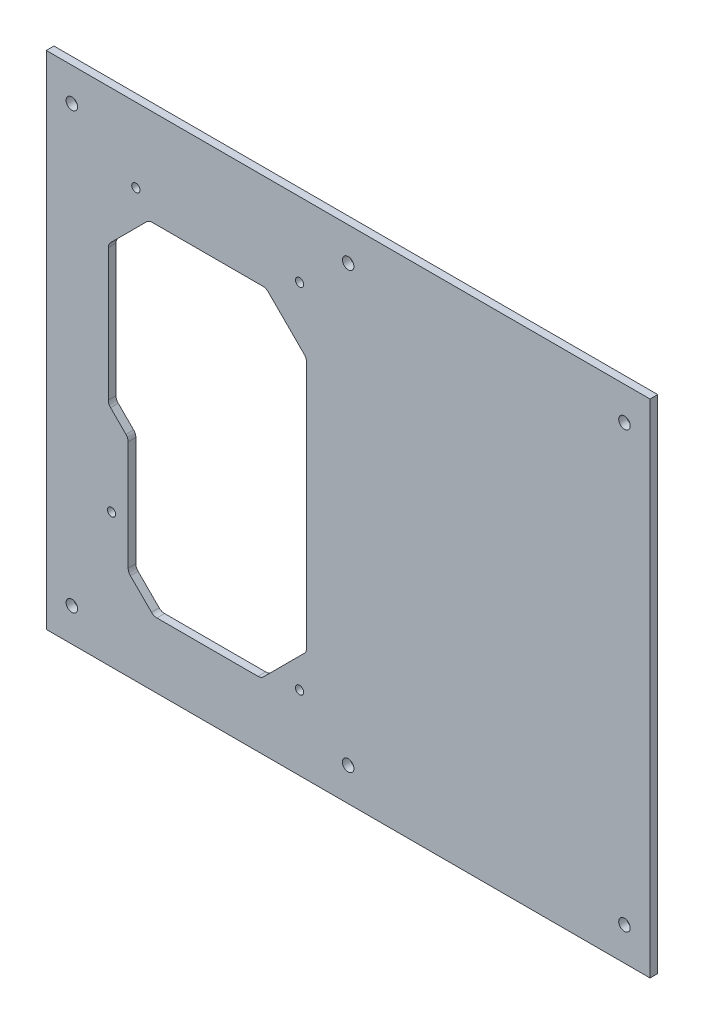
from build123d import *

# Parameters (mm, degrees)
SKETCH_1_W          = 236
SKETCH_1_H          = 196
SKETCH_1_R          = 2.25
EXTRUDE_1_DEPTH     = 3
SKETCH_2_R          = 1.6
CUT_EXTRUDE_2_DEPTH = 4
FILLET_1_R          = 3


with BuildPart() as part:
    # Эскиз1 → Бобышка-Вытянуть1 (new body)
    with BuildSketch(Plane.XY):
        with Locations((118, 98)):
            Rectangle(SKETCH_1_W, SKETCH_1_H)
        with Locations((10, 183)):
            Circle(SKETCH_1_R, mode=Mode.SUBTRACT)
        with Locations((10, 13)):
            Circle(SKETCH_1_R, mode=Mode.SUBTRACT)
        with Locations((226, 183)):
            Circle(SKETCH_1_R, mode=Mode.SUBTRACT)
        with Locations((226, 13)):
            Circle(SKETCH_1_R, mode=Mode.SUBTRACT)
        with Locations((118, 183)):
            Circle(SKETCH_1_R, mode=Mode.SUBTRACT)
        with Locations((118, 13)):
            Circle(SKETCH_1_R, mode=Mode.SUBTRACT)
    extrude(amount=EXTRUDE_1_DEPTH)

    # Эскиз2 → Вырез-Вытянуть2 (cut, through all)
    with BuildSketch(Plane.XY):
        with Locations((25.5, 52.5)):
            Circle(SKETCH_2_R)
        with Locations((99, 29)):
            Circle(SKETCH_2_R)
        with Locations((35, 167)):
            Circle(SKETCH_2_R)
        with Locations((99, 167)):
            Circle(SKETCH_2_R)
        Polygon((101.75, 142.628747105), (85.878747105, 158.5), (40.121211423, 158.5), (24.25, 142.628788577), (24.25, 88.5), (32, 80.75), (32, 35.5), (42, 25.5), (84, 25.5), (101.75, 43.25), align=None)
    extrude(amount=CUT_EXTRUDE_2_DEPTH, mode=Mode.SUBTRACT)

    # Скругление1
    fillet_1_edges = [part.edges().sort_by_distance(p)[0] for p in [
        (40.121211423, 158.5, 1.5),
        (24.25, 142.628788577, 1.5),
        (24.25, 88.5, 1.5),
        (32, 80.75, 1.5),
        (32, 35.5, 1.5),
        (42, 25.5, 1.5),
        (84, 25.5, 1.5),
        (101.75, 43.25, 1.5),
        (101.75, 142.628747105, 1.5),
        (85.878747105, 158.5, 1.5),
    ]]
    fillet(fillet_1_edges, radius=FILLET_1_R)


solid = part.part
